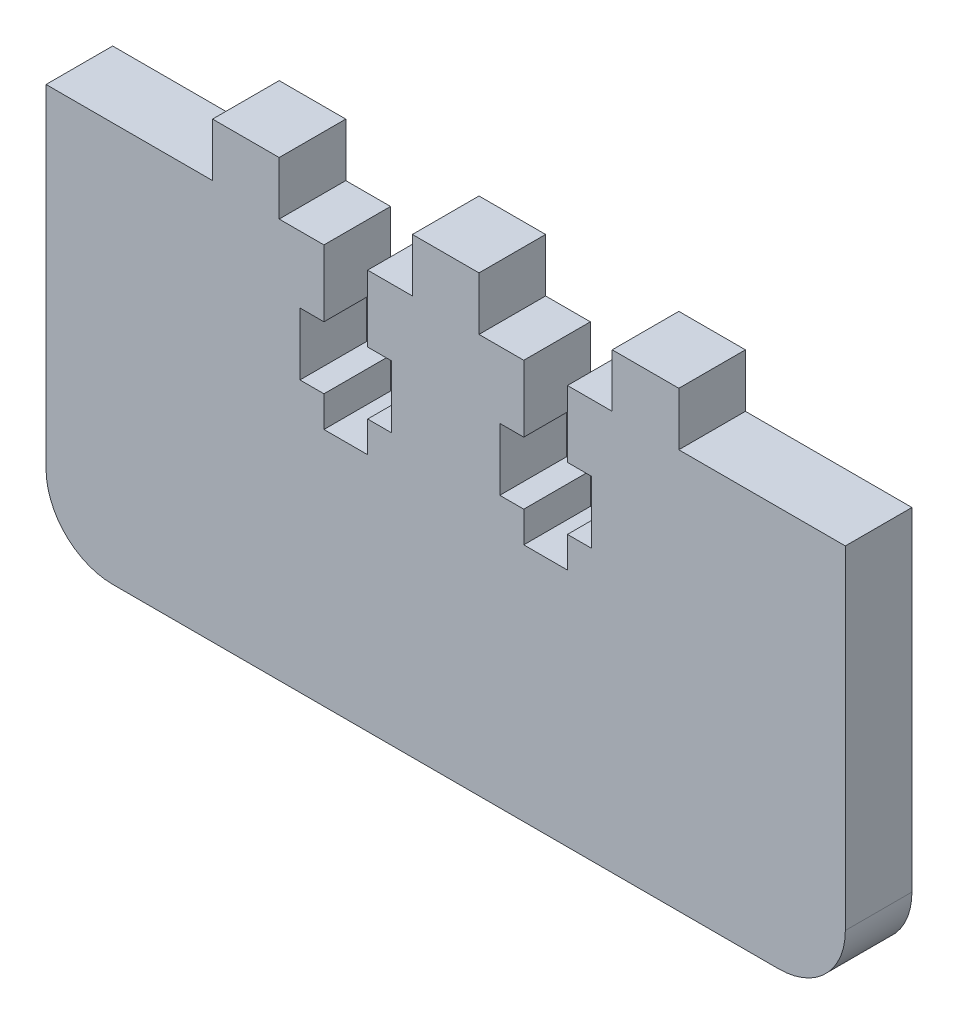
from build123d import *

# Parameters (mm, degrees)
SKETCH1_W           = 76.2
SKETCH1_H           = 38.1
BOSS_EXTRUDE1_DEPTH = 6.35
SKETCH3_W           = 6.35
SKETCH3_H           = 5.08
BOSS_EXTRUDE2_DEPTH = 6.35
CUT_EXTRUDE1_DEPTH  = 7.35
FILLET1_R           = 6.35


with BuildPart() as part:
    # Sketch1 → Boss-Extrude1 (new body)
    with BuildSketch(Plane.XY):
        Rectangle(SKETCH1_W, SKETCH1_H)
    extrude(amount=BOSS_EXTRUDE1_DEPTH)

    # Sketch3 → Boss-Extrude2 (add)
    with BuildSketch(Plane.XY.offset(6.35)):
        with Locations((19.05, 21.59)):
            Rectangle(SKETCH3_W, SKETCH3_H)
        with Locations((-19.05, 21.59)):
            Rectangle(SKETCH3_W, SKETCH3_H)
        with Locations((0, 21.59)):
            Rectangle(SKETCH3_W, SKETCH3_H)
    extrude(amount=-BOSS_EXTRUDE2_DEPTH)

    # Sketch6 → Cut-Extrude1 (cut, through all)
    with BuildSketch(Plane.XY.offset(6.35)):
        Polygon((-11.6078, 19.05), (-11.6078, 12.7), (-13.8938, 12.7), (-13.8938, 6.7564), (-11.6078, 6.7564), (-11.6078, 3.81), (-7.4422, 3.81), (-7.4422, 6.7564), (-5.1562, 6.7564), (-5.1562, 12.7), (-7.4422, 12.7), (-7.4422, 19.05), align=None)
        Polygon((7.4422, 19.05), (7.4422, 12.7), (5.1562, 12.7), (5.1562, 6.7564), (7.4422, 6.7564), (7.4422, 3.81), (11.6078, 3.81), (11.6078, 6.7564), (13.8938, 6.7564), (13.8938, 12.7), (11.6078, 12.7), (11.6078, 19.05), align=None)
    extrude(amount=-CUT_EXTRUDE1_DEPTH, mode=Mode.SUBTRACT)

    # Fillet1
    fillet1_edges = [part.edges().sort_by_distance(p)[0] for p in [
        (38.1, -19.05, 3.175),
        (-38.1, -19.05, 3.175),
    ]]
    fillet(fillet1_edges, radius=FILLET1_R)


solid = part.part
